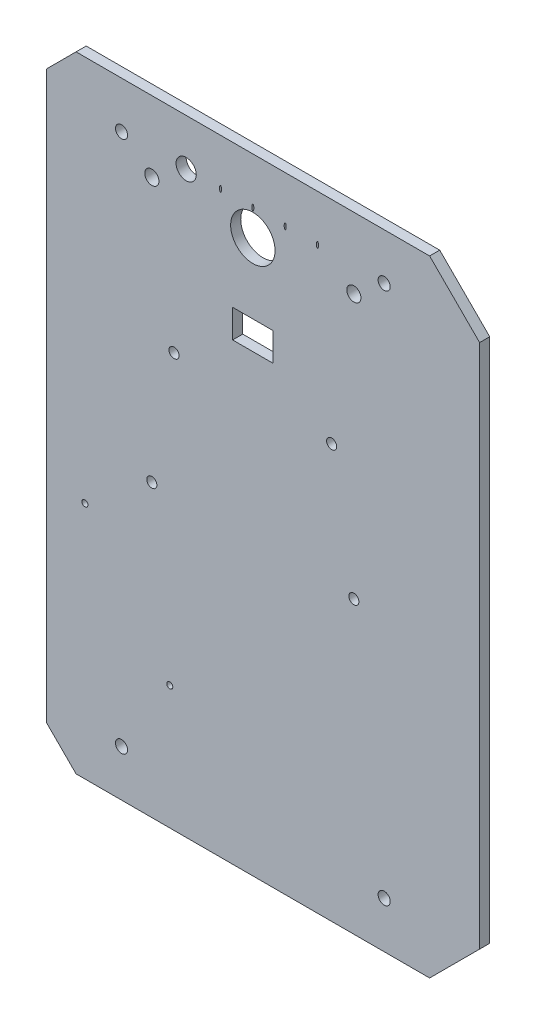
from build123d import *

# Parameters (mm, degrees)
BASE_DEPTH               = 5
ESQUISSE8_R              = 5
ENL_V_MAT_EXTRU_7_DEPTH  = 10
ESQUISSE4_R              = 11
ESQUISSE4_R_2            = 3.5
ESQUISSE4_RX             = 1.5
ESQUISSE4_RY             = 0.5
ESQUISSE4_W              = 20
ESQUISSE4_H              = 14
ENL_V_MAT_EXTRU_8_DEPTH  = 10
ESQUISSE2_R              = 3
ESQUISSE2_R_2            = 2.5
ENL_V_MAT_EXTRU_9_DEPTH  = 10
ESQUISSE11_R             = 1.5
ENL_V_MAT_EXTRU_11_DEPTH = 5


with BuildPart() as part:
    # Esquisse1 → Base (new body)
    with BuildSketch(Plane.XY):
        Polygon((0, 0), (-175, 0), (-199.748737342, 24.748737342), (-199.748737342, 284.748737342), (-175, 309.497474683), (0, 309.497474683), (24.748737342, 284.748737342), (24.748737342, 24.748737342), align=None)
    extrude(amount=BASE_DEPTH)

    # Esquisse8 → Enlèv. mat.-Extru.7 (cut)
    with BuildSketch(Plane.XY.offset(5)):
        with Locations((-120.5, 286.497474683)):
            Circle(ESQUISSE8_R)
    extrude(amount=-ENL_V_MAT_EXTRU_7_DEPTH, mode=Mode.SUBTRACT)

    # Esquisse4 → Enlèv. mat.-Extru.8 (cut)
    with BuildSketch(Plane.XY.offset(5)):
        with Locations((-87.5, 273.497474683)):
            Circle(ESQUISSE4_R)
        with Locations((-137.5, 274.497474683)):
            Circle(ESQUISSE4_R_2)
        with Locations((-37.5, 274.497474683)):
            Circle(ESQUISSE4_R_2)
        with Locations(Location((-103.5, 286.497474683), (0, 0, -90))):
            Ellipse(ESQUISSE4_RX, ESQUISSE4_RY)
        with Locations(Location((-87.5, 286.497474683), (0, 0, -90))):
            Ellipse(ESQUISSE4_RX, ESQUISSE4_RY)
        with Locations(Location((-71.5, 286.497474683), (0, 0, -90))):
            Ellipse(ESQUISSE4_RX, ESQUISSE4_RY)
        with Locations(Location((-55.5, 286.497474683), (0, 0, -90))):
            Ellipse(ESQUISSE4_RX, ESQUISSE4_RY)
        with Locations((-87.5, 231.748737342)):
            Rectangle(ESQUISSE4_W, ESQUISSE4_H)
    extrude(amount=-ENL_V_MAT_EXTRU_8_DEPTH, mode=Mode.SUBTRACT)

    # Esquisse2 → Enlèv. mat.-Extru.9 (cut)
    with BuildSketch(Plane.XY.offset(5)):
        with Locations((-152.498737342, 23)):
            Circle(ESQUISSE2_R)
        with Locations((-152.498737342, 286.497474683)):
            Circle(ESQUISSE2_R)
        with Locations((-22.501262658, 23)):
            Circle(ESQUISSE2_R)
        with Locations((-22.501262658, 286.497474683)):
            Circle(ESQUISSE2_R)
        with Locations((-137.5, 143.748737342)):
            Circle(ESQUISSE2_R_2)
        with Locations((-126.5, 204.748737342)):
            Circle(ESQUISSE2_R_2)
        with Locations((-37.5, 143.748737342)):
            Circle(ESQUISSE2_R_2)
        with Locations((-48.5, 204.748737342)):
            Circle(ESQUISSE2_R_2)
    extrude(amount=-ENL_V_MAT_EXTRU_9_DEPTH, mode=Mode.SUBTRACT)

    # Esquisse11 → Enlèv. mat.-Extru.11 (cut)
    with BuildSketch(Plane.XY.offset(5)):
        with Locations((-170.614939475, 118.152371839)):
            Circle(ESQUISSE11_R)
        with Locations((-128.614939475, 61.152371839)):
            Circle(ESQUISSE11_R)
        Polygon((-189.748737342, -12.261016229), (-189.748737342, 134.748737342), (-189.748737342, 326.523808624), (-199.748737342, 326.523808624), (-199.748737342, -12.261016229), align=None)
    extrude(amount=-ENL_V_MAT_EXTRU_11_DEPTH, mode=Mode.SUBTRACT)


solid = part.part
